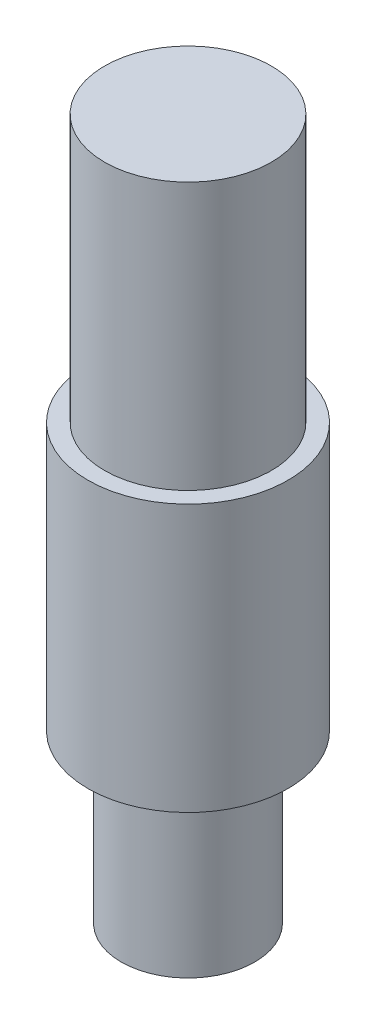
from build123d import *

# Parameters (mm, degrees)
SKETCH1_R           = 10
BOSS_EXTRUDE3_DEPTH = 25
SKETCH5_R           = 14.99
BOSS_EXTRUDE4_DEPTH = 40
SKETCH6_R           = 12.49
BOSS_EXTRUDE5_DEPTH = 40


with BuildPart() as part:
    # Sketch1 → Boss-Extrude3 (new body)
    with BuildSketch(Plane(origin=(0, 0, 0), x_dir=(1, 0, 0), z_dir=(0, 1, 0))):
        Circle(SKETCH1_R)
    extrude(amount=BOSS_EXTRUDE3_DEPTH)

    # Sketch5 → Boss-Extrude4 (add)
    with BuildSketch(Plane(origin=(0, 25, 0), x_dir=(1, 0, 0), z_dir=(0, 1, 0))):
        Circle(SKETCH5_R)
    extrude(amount=BOSS_EXTRUDE4_DEPTH)

    # Sketch6 → Boss-Extrude5 (add)
    with BuildSketch(Plane(origin=(0, 65, 0), x_dir=(1, 0, 0), z_dir=(0, 1, 0))):
        Circle(SKETCH6_R)
    extrude(amount=BOSS_EXTRUDE5_DEPTH)


solid = part.part
